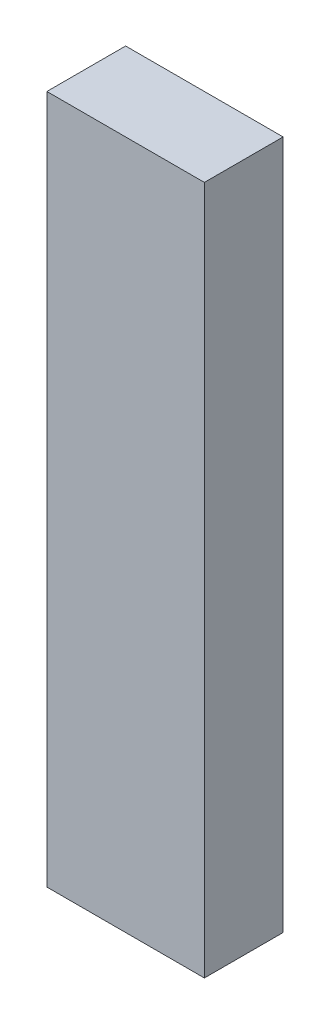
from build123d import *

# Parameters (mm, degrees)
SKETCH1_W           = 8
SKETCH1_H           = 35
BOSS_EXTRUDE1_DEPTH = 4


with BuildPart() as part:
    # Sketch1 → Boss-Extrude1 (new body)
    with BuildSketch(Plane.XY):
        Rectangle(SKETCH1_W, SKETCH1_H)
    extrude(amount=BOSS_EXTRUDE1_DEPTH)


solid = part.part
